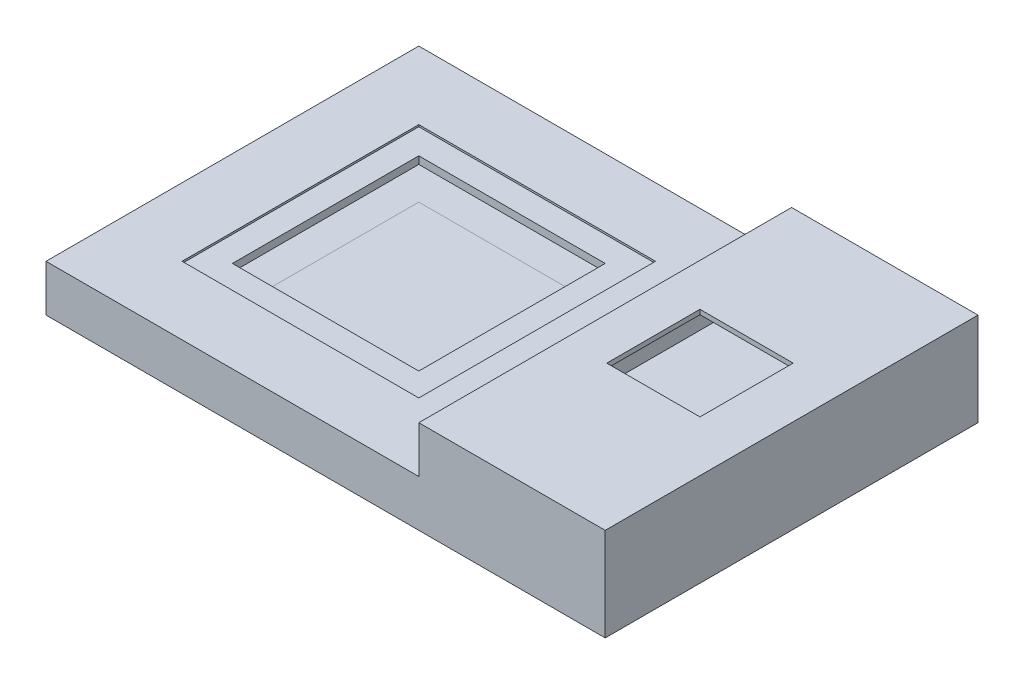
from build123d import *

# Parameters (mm, degrees)
SKETCH1_W                = 40
SKETCH1_H                = 40
SKETCH1_W_2              = 20
SKETCH1_H_2              = 20
BOSS_EXTRUDE1_DEPTH      = 5
BOSS_EXTRUDE2_DEPTH      = 5
BOSS_EXTRUDE2_DEPTH_BACK = 5
SKETCH1_4_W              = 20
SKETCH1_4_H              = 40
SKETCH2_W                = 25.4
SKETCH2_H                = 25.4
CUT_EXTRUDE1_DEPTH       = 0.2
CUT_EXTRUDE2_DEPTH       = 19.5
CUT_EXTRUDE2_DEPTH_BACK  = 19.5
SKETCH3_W                = 59
SKETCH3_H                = 3.5
CUT_EXTRUDE3_DEPTH       = 19.5
CUT_EXTRUDE3_DEPTH_BACK  = 19.5
SKETCH4_W                = 10
SKETCH4_H                = 10
CUT_EXTRUDE4_DEPTH       = 2
SKETCH7_W                = 20
SKETCH7_H                = 20
BOSS_EXTRUDE3_DEPTH      = 0.5


with BuildPart() as part:
    # Sketch1 → Boss-Extrude1 (new body)
    with BuildSketch(Plane(origin=(0, 0, 0), x_dir=(1, 0, 0), z_dir=(0, 1, 0))):
        Rectangle(SKETCH1_W, SKETCH1_H)
        Rectangle(SKETCH1_W_2, SKETCH1_H_2, mode=Mode.SUBTRACT)
    extrude(amount=-BOSS_EXTRUDE1_DEPTH)

    # Sketch1_4 → Boss-Extrude2 (add, two sides: drawn at the far end of the back side and taken through both)
    with BuildSketch(Plane(origin=(0, 0, 0), x_dir=(1, 0, 0), z_dir=(0, 1, 0)).offset(-BOSS_EXTRUDE2_DEPTH_BACK)):
        with Locations((30, 0)):
            Rectangle(SKETCH1_4_W, SKETCH1_4_H)
    extrude(amount=BOSS_EXTRUDE2_DEPTH + BOSS_EXTRUDE2_DEPTH_BACK)

    # Sketch2 → Cut-Extrude1 (cut)
    with BuildSketch(Plane(origin=(0, 0, 0), x_dir=(1, 0, 0), z_dir=(0, 1, 0))):
        Rectangle(SKETCH2_W, SKETCH2_H)
    extrude(amount=-CUT_EXTRUDE1_DEPTH, mode=Mode.SUBTRACT)

    # Sketch3 → Cut-Extrude2 (cut, two sides: drawn at the far end of the back side and taken through both)
    with BuildSketch(Plane.XY.offset(-CUT_EXTRUDE2_DEPTH_BACK)):
        with Locations((10, -2.75)):
            Rectangle(SKETCH3_W, SKETCH3_H)
    extrude(amount=CUT_EXTRUDE2_DEPTH + CUT_EXTRUDE2_DEPTH_BACK, mode=Mode.SUBTRACT)

    # Sketch5 → Cut-Extrude3 (cut, two sides: drawn at the far end of the back side and taken through both)
    with BuildSketch(Plane.XY.offset(-CUT_EXTRUDE3_DEPTH_BACK)):
        Polygon((39.5, -4.5), (20.5, -4.5), (20, -4.5), (20, -1), (20.5, -1), (20.5, 4.5), (39.5, 4.5), align=None)
    extrude(amount=CUT_EXTRUDE3_DEPTH + CUT_EXTRUDE3_DEPTH_BACK, mode=Mode.SUBTRACT)

    # Sketch4 → Cut-Extrude4 (cut)
    with BuildSketch(Plane(origin=(0, 5, 0), x_dir=(1, 0, 0), z_dir=(0, 1, 0))):
        with Locations((29.545931586, 0.622908533)):
            Rectangle(SKETCH4_W, SKETCH4_H)
    extrude(amount=-CUT_EXTRUDE4_DEPTH, mode=Mode.SUBTRACT)


with BuildPart() as body_2:
    # Sketch7 → Boss-Extrude3 (new body)
    with BuildSketch(Plane(origin=(0, -4.5, 0), x_dir=(1, 0, 0), z_dir=(0, 1, 0))):
        Rectangle(SKETCH7_W, SKETCH7_H)
    extrude(amount=-BOSS_EXTRUDE3_DEPTH)


solid = Compound([part.part, body_2.part])
